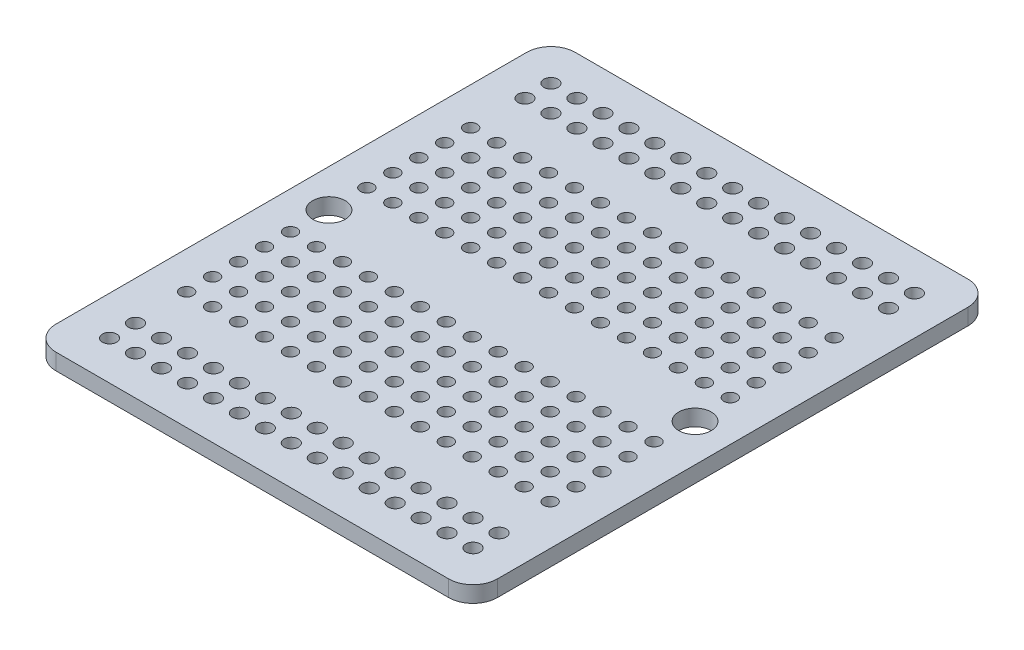
from build123d import *

# Parameters (mm, degrees)
SKETCH1_W                 = 43.18
SKETCH1_H                 = 50.8
BOSS_EXTRUDE1_DEPTH       = 1.5875
FILLET1_R                 = 2.38125
SKETCH4_R                 = 0.6985
CUT_EXTRUDE1_DEPTH        = 34.373765988
LPATTERN1_COUNT           = 15
LPATTERN1_PITCH           = 2.54
LPATTERN1_COUNT_DIR2      = 2
LPATTERN1_PITCH_DIR2      = 2.54
SKETCH5_R                 = 0.635
CUT_EXTRUDE6_DEPTH        = 34.373765988
LPATTERN2_COUNT           = 15
LPATTERN2_PITCH           = 2.54
LPATTERN2_COUNT_DIR2      = 5
LPATTERN2_PITCH_DIR2      = 2.54
MIRROR1_COPY_1_SKETCH_R   = 0.6985
MIRROR1_COPY_1_DEPTH      = 34.373765988
MIRROR1_COPY_2_SKETCH_R   = 0.6985
MIRROR1_COPY_2_DEPTH      = 34.373765988
MIRROR1_COPY_3_SKETCH_R   = 0.6985
MIRROR1_COPY_3_DEPTH      = 34.373765988
MIRROR1_COPY_4_SKETCH_R   = 0.6985
MIRROR1_COPY_4_DEPTH      = 34.373765988
MIRROR1_COPY_5_SKETCH_R   = 0.6985
MIRROR1_COPY_5_DEPTH      = 34.373765988
MIRROR1_COPY_6_SKETCH_R   = 0.6985
MIRROR1_COPY_6_DEPTH      = 34.373765988
MIRROR1_COPY_7_SKETCH_R   = 0.6985
MIRROR1_COPY_7_DEPTH      = 34.373765988
MIRROR1_COPY_8_SKETCH_R   = 0.6985
MIRROR1_COPY_8_DEPTH      = 34.373765988
MIRROR1_COPY_9_SKETCH_R   = 0.6985
MIRROR1_COPY_9_DEPTH      = 34.373765988
MIRROR1_COPY_10_SKETCH_R  = 0.6985
MIRROR1_COPY_10_DEPTH     = 34.373765988
MIRROR1_COPY_11_SKETCH_R  = 0.6985
MIRROR1_COPY_11_DEPTH     = 34.373765988
MIRROR1_COPY_12_SKETCH_R  = 0.6985
MIRROR1_COPY_12_DEPTH     = 34.373765988
MIRROR1_COPY_13_SKETCH_R  = 0.6985
MIRROR1_COPY_13_DEPTH     = 34.373765988
MIRROR1_COPY_14_SKETCH_R  = 0.6985
MIRROR1_COPY_14_DEPTH     = 34.373765988
MIRROR1_COPY_15_SKETCH_R  = 0.6985
MIRROR1_COPY_15_DEPTH     = 34.373765988
MIRROR1_COPY_16_SKETCH_R  = 0.6985
MIRROR1_COPY_16_DEPTH     = 34.373765988
MIRROR1_COPY_17_SKETCH_R  = 0.6985
MIRROR1_COPY_17_DEPTH     = 34.373765988
MIRROR1_COPY_18_SKETCH_R  = 0.6985
MIRROR1_COPY_18_DEPTH     = 34.373765988
MIRROR1_COPY_19_SKETCH_R  = 0.6985
MIRROR1_COPY_19_DEPTH     = 34.373765988
MIRROR1_COPY_20_SKETCH_R  = 0.6985
MIRROR1_COPY_20_DEPTH     = 34.373765988
MIRROR1_COPY_21_SKETCH_R  = 0.6985
MIRROR1_COPY_21_DEPTH     = 34.373765988
MIRROR1_COPY_22_SKETCH_R  = 0.6985
MIRROR1_COPY_22_DEPTH     = 34.373765988
MIRROR1_COPY_23_SKETCH_R  = 0.6985
MIRROR1_COPY_23_DEPTH     = 34.373765988
MIRROR1_COPY_24_SKETCH_R  = 0.6985
MIRROR1_COPY_24_DEPTH     = 34.373765988
MIRROR1_COPY_25_SKETCH_R  = 0.6985
MIRROR1_COPY_25_DEPTH     = 34.373765988
MIRROR1_COPY_26_SKETCH_R  = 0.6985
MIRROR1_COPY_26_DEPTH     = 34.373765988
MIRROR1_COPY_27_SKETCH_R  = 0.6985
MIRROR1_COPY_27_DEPTH     = 34.373765988
MIRROR1_COPY_28_SKETCH_R  = 0.6985
MIRROR1_COPY_28_DEPTH     = 34.373765988
MIRROR1_COPY_29_SKETCH_R  = 0.6985
MIRROR1_COPY_29_DEPTH     = 34.373765988
MIRROR1_COPY_30_SKETCH_R  = 0.635
MIRROR1_COPY_30_DEPTH     = 34.373765988
MIRROR1_COPY_31_SKETCH_R  = 0.635
MIRROR1_COPY_31_DEPTH     = 34.373765988
MIRROR1_COPY_32_SKETCH_R  = 0.635
MIRROR1_COPY_32_DEPTH     = 34.373765988
MIRROR1_COPY_33_SKETCH_R  = 0.635
MIRROR1_COPY_33_DEPTH     = 34.373765988
MIRROR1_COPY_34_SKETCH_R  = 0.635
MIRROR1_COPY_34_DEPTH     = 34.373765988
MIRROR1_COPY_35_SKETCH_R  = 0.635
MIRROR1_COPY_35_DEPTH     = 34.373765988
MIRROR1_COPY_36_SKETCH_R  = 0.635
MIRROR1_COPY_36_DEPTH     = 34.373765988
MIRROR1_COPY_37_SKETCH_R  = 0.635
MIRROR1_COPY_37_DEPTH     = 34.373765988
MIRROR1_COPY_38_SKETCH_R  = 0.635
MIRROR1_COPY_38_DEPTH     = 34.373765988
MIRROR1_COPY_39_SKETCH_R  = 0.635
MIRROR1_COPY_39_DEPTH     = 34.373765988
MIRROR1_COPY_40_SKETCH_R  = 0.635
MIRROR1_COPY_40_DEPTH     = 34.373765988
MIRROR1_COPY_41_SKETCH_R  = 0.635
MIRROR1_COPY_41_DEPTH     = 34.373765988
MIRROR1_COPY_42_SKETCH_R  = 0.635
MIRROR1_COPY_42_DEPTH     = 34.373765988
MIRROR1_COPY_43_SKETCH_R  = 0.635
MIRROR1_COPY_43_DEPTH     = 34.373765988
MIRROR1_COPY_44_SKETCH_R  = 0.635
MIRROR1_COPY_44_DEPTH     = 34.373765988
MIRROR1_COPY_45_SKETCH_R  = 0.635
MIRROR1_COPY_45_DEPTH     = 34.373765988
MIRROR1_COPY_46_SKETCH_R  = 0.635
MIRROR1_COPY_46_DEPTH     = 34.373765988
MIRROR1_COPY_47_SKETCH_R  = 0.635
MIRROR1_COPY_47_DEPTH     = 34.373765988
MIRROR1_COPY_48_SKETCH_R  = 0.635
MIRROR1_COPY_48_DEPTH     = 34.373765988
MIRROR1_COPY_49_SKETCH_R  = 0.635
MIRROR1_COPY_49_DEPTH     = 34.373765988
MIRROR1_COPY_50_SKETCH_R  = 0.635
MIRROR1_COPY_50_DEPTH     = 34.373765988
MIRROR1_COPY_51_SKETCH_R  = 0.635
MIRROR1_COPY_51_DEPTH     = 34.373765988
MIRROR1_COPY_52_SKETCH_R  = 0.635
MIRROR1_COPY_52_DEPTH     = 34.373765988
MIRROR1_COPY_53_SKETCH_R  = 0.635
MIRROR1_COPY_53_DEPTH     = 34.373765988
MIRROR1_COPY_54_SKETCH_R  = 0.635
MIRROR1_COPY_54_DEPTH     = 34.373765988
MIRROR1_COPY_55_SKETCH_R  = 0.635
MIRROR1_COPY_55_DEPTH     = 34.373765988
MIRROR1_COPY_56_SKETCH_R  = 0.635
MIRROR1_COPY_56_DEPTH     = 34.373765988
MIRROR1_COPY_57_SKETCH_R  = 0.635
MIRROR1_COPY_57_DEPTH     = 34.373765988
MIRROR1_COPY_58_SKETCH_R  = 0.635
MIRROR1_COPY_58_DEPTH     = 34.373765988
MIRROR1_COPY_59_SKETCH_R  = 0.635
MIRROR1_COPY_59_DEPTH     = 34.373765988
MIRROR1_COPY_60_SKETCH_R  = 0.635
MIRROR1_COPY_60_DEPTH     = 34.373765988
MIRROR1_COPY_61_SKETCH_R  = 0.635
MIRROR1_COPY_61_DEPTH     = 34.373765988
MIRROR1_COPY_62_SKETCH_R  = 0.635
MIRROR1_COPY_62_DEPTH     = 34.373765988
MIRROR1_COPY_63_SKETCH_R  = 0.635
MIRROR1_COPY_63_DEPTH     = 34.373765988
MIRROR1_COPY_64_SKETCH_R  = 0.635
MIRROR1_COPY_64_DEPTH     = 34.373765988
MIRROR1_COPY_65_SKETCH_R  = 0.635
MIRROR1_COPY_65_DEPTH     = 34.373765988
MIRROR1_COPY_66_SKETCH_R  = 0.635
MIRROR1_COPY_66_DEPTH     = 34.373765988
MIRROR1_COPY_67_SKETCH_R  = 0.635
MIRROR1_COPY_67_DEPTH     = 34.373765988
MIRROR1_COPY_68_SKETCH_R  = 0.635
MIRROR1_COPY_68_DEPTH     = 34.373765988
MIRROR1_COPY_69_SKETCH_R  = 0.635
MIRROR1_COPY_69_DEPTH     = 34.373765988
MIRROR1_COPY_70_SKETCH_R  = 0.635
MIRROR1_COPY_70_DEPTH     = 34.373765988
MIRROR1_COPY_71_SKETCH_R  = 0.635
MIRROR1_COPY_71_DEPTH     = 34.373765988
MIRROR1_COPY_72_SKETCH_R  = 0.635
MIRROR1_COPY_72_DEPTH     = 34.373765988
MIRROR1_COPY_73_SKETCH_R  = 0.635
MIRROR1_COPY_73_DEPTH     = 34.373765988
MIRROR1_COPY_74_SKETCH_R  = 0.635
MIRROR1_COPY_74_DEPTH     = 34.373765988
MIRROR1_COPY_75_SKETCH_R  = 0.635
MIRROR1_COPY_75_DEPTH     = 34.373765988
MIRROR1_COPY_76_SKETCH_R  = 0.635
MIRROR1_COPY_76_DEPTH     = 34.373765988
MIRROR1_COPY_77_SKETCH_R  = 0.635
MIRROR1_COPY_77_DEPTH     = 34.373765988
MIRROR1_COPY_78_SKETCH_R  = 0.635
MIRROR1_COPY_78_DEPTH     = 34.373765988
MIRROR1_COPY_79_SKETCH_R  = 0.635
MIRROR1_COPY_79_DEPTH     = 34.373765988
MIRROR1_COPY_80_SKETCH_R  = 0.635
MIRROR1_COPY_80_DEPTH     = 34.373765988
MIRROR1_COPY_81_SKETCH_R  = 0.635
MIRROR1_COPY_81_DEPTH     = 34.373765988
MIRROR1_COPY_82_SKETCH_R  = 0.635
MIRROR1_COPY_82_DEPTH     = 34.373765988
MIRROR1_COPY_83_SKETCH_R  = 0.635
MIRROR1_COPY_83_DEPTH     = 34.373765988
MIRROR1_COPY_84_SKETCH_R  = 0.635
MIRROR1_COPY_84_DEPTH     = 34.373765988
MIRROR1_COPY_85_SKETCH_R  = 0.635
MIRROR1_COPY_85_DEPTH     = 34.373765988
MIRROR1_COPY_86_SKETCH_R  = 0.635
MIRROR1_COPY_86_DEPTH     = 34.373765988
MIRROR1_COPY_87_SKETCH_R  = 0.635
MIRROR1_COPY_87_DEPTH     = 34.373765988
MIRROR1_COPY_88_SKETCH_R  = 0.635
MIRROR1_COPY_88_DEPTH     = 34.373765988
MIRROR1_COPY_89_SKETCH_R  = 0.635
MIRROR1_COPY_89_DEPTH     = 34.373765988
MIRROR1_COPY_90_SKETCH_R  = 0.635
MIRROR1_COPY_90_DEPTH     = 34.373765988
MIRROR1_COPY_91_SKETCH_R  = 0.635
MIRROR1_COPY_91_DEPTH     = 34.373765988
MIRROR1_COPY_92_SKETCH_R  = 0.635
MIRROR1_COPY_92_DEPTH     = 34.373765988
MIRROR1_COPY_93_SKETCH_R  = 0.635
MIRROR1_COPY_93_DEPTH     = 34.373765988
MIRROR1_COPY_94_SKETCH_R  = 0.635
MIRROR1_COPY_94_DEPTH     = 34.373765988
MIRROR1_COPY_95_SKETCH_R  = 0.635
MIRROR1_COPY_95_DEPTH     = 34.373765988
MIRROR1_COPY_96_SKETCH_R  = 0.635
MIRROR1_COPY_96_DEPTH     = 34.373765988
MIRROR1_COPY_97_SKETCH_R  = 0.635
MIRROR1_COPY_97_DEPTH     = 34.373765988
MIRROR1_COPY_98_SKETCH_R  = 0.635
MIRROR1_COPY_98_DEPTH     = 34.373765988
MIRROR1_COPY_99_SKETCH_R  = 0.635
MIRROR1_COPY_99_DEPTH     = 34.373765988
MIRROR1_COPY_100_SKETCH_R = 0.635
MIRROR1_COPY_100_DEPTH    = 34.373765988
MIRROR1_COPY_101_SKETCH_R = 0.635
MIRROR1_COPY_101_DEPTH    = 34.373765988
MIRROR1_COPY_102_SKETCH_R = 0.635
MIRROR1_COPY_102_DEPTH    = 34.373765988
MIRROR1_COPY_103_SKETCH_R = 0.635
MIRROR1_COPY_103_DEPTH    = 34.373765988
SKETCH6_R                 = 1.5875
CUT_EXTRUDE7_DEPTH        = 34.373765988


with BuildPart() as part:
    # Sketch1 → Boss-Extrude1 (new body)
    with BuildSketch(Plane(origin=(0, 0, 0), x_dir=(1, 0, 0), z_dir=(0, 1, 0))):
        Rectangle(SKETCH1_W, SKETCH1_H)
    extrude(amount=BOSS_EXTRUDE1_DEPTH)

    # Fillet1
    fillet1_edges = [part.edges().sort_by_distance(p)[0] for p in [
        (21.59, 0.79375, 25.4),
        (-21.59, 0.79375, 25.4),
        (-21.59, 0.79375, -25.4),
        (21.59, 0.79375, -25.4),
    ]]
    fillet(fillet1_edges, radius=FILLET1_R)

    # Sketch4 → Cut-Extrude1 (cut, through all)
    with BuildSketch(Plane(origin=(0, 1.5875, 0), x_dir=(1, 0, 0), z_dir=(0, 1, 0))):
        with Locations(Location((-17.78, 21.59, 0), (0, 0, 270))):
            Circle(SKETCH4_R)
    cut_extrude1 = extrude(amount=-CUT_EXTRUDE1_DEPTH, mode=Mode.SUBTRACT)

    # LPattern1: Cut-Extrude1 15 × 2
    with Locations(*[(i * LPATTERN1_PITCH, 0, j * LPATTERN1_PITCH_DIR2) for i in range(LPATTERN1_COUNT) for j in range(LPATTERN1_COUNT_DIR2) if (i, j) != (0, 0)]):
        add(cut_extrude1, mode=Mode.SUBTRACT)

    # Sketch5 → Cut-Extrude6 (cut, through all)
    with BuildSketch(Plane(origin=(0, 0, 0), x_dir=(1, 0, 0), z_dir=(0, 1, 0))):
        with Locations(Location((-17.935079329, 13.893307041, 0), (0, 0, 270))):
            Circle(SKETCH5_R)
    cut_extrude6 = extrude(amount=CUT_EXTRUDE6_DEPTH, mode=Mode.SUBTRACT)

    # LPattern2: Cut-Extrude6 15 × 5
    with Locations(*[(i * LPATTERN2_PITCH, 0, j * LPATTERN2_PITCH_DIR2) for i in range(LPATTERN2_COUNT) for j in range(LPATTERN2_COUNT_DIR2) if (i, j) != (0, 0)]):
        add(cut_extrude6, mode=Mode.SUBTRACT)

    # Mirror1: Cut-Extrude1, Cut-Extrude6 across plane
    add(cut_extrude1.mirror(Plane.XY), mode=Mode.SUBTRACT)
    add(cut_extrude6.mirror(Plane.XY), mode=Mode.SUBTRACT)

    # Mirror1 copy 1 sketch → Mirror1 copy 1 (cut, through all)
    with BuildSketch(Plane(origin=(0, 1.5875, -2.54), x_dir=(1, 0, 0), z_dir=(0, 1, 0))):
        with Locations((-17.78, -21.59)):
            Circle(MIRROR1_COPY_1_SKETCH_R)
    extrude(amount=-MIRROR1_COPY_1_DEPTH, mode=Mode.SUBTRACT)

    # Mirror1 copy 2 sketch → Mirror1 copy 2 (cut, through all)
    with BuildSketch(Plane(origin=(2.54, 1.5875, 0), x_dir=(1, 0, 0), z_dir=(0, 1, 0))):
        with Locations((-17.78, -21.59)):
            Circle(MIRROR1_COPY_2_SKETCH_R)
    extrude(amount=-MIRROR1_COPY_2_DEPTH, mode=Mode.SUBTRACT)

    # Mirror1 copy 3 sketch → Mirror1 copy 3 (cut, through all)
    with BuildSketch(Plane(origin=(2.54, 1.5875, -2.54), x_dir=(1, 0, 0), z_dir=(0, 1, 0))):
        with Locations((-17.78, -21.59)):
            Circle(MIRROR1_COPY_3_SKETCH_R)
    extrude(amount=-MIRROR1_COPY_3_DEPTH, mode=Mode.SUBTRACT)

    # Mirror1 copy 4 sketch → Mirror1 copy 4 (cut, through all)
    with BuildSketch(Plane(origin=(5.08, 1.5875, 0), x_dir=(1, 0, 0), z_dir=(0, 1, 0))):
        with Locations((-17.78, -21.59)):
            Circle(MIRROR1_COPY_4_SKETCH_R)
    extrude(amount=-MIRROR1_COPY_4_DEPTH, mode=Mode.SUBTRACT)

    # Mirror1 copy 5 sketch → Mirror1 copy 5 (cut, through all)
    with BuildSketch(Plane(origin=(5.08, 1.5875, -2.54), x_dir=(1, 0, 0), z_dir=(0, 1, 0))):
        with Locations((-17.78, -21.59)):
            Circle(MIRROR1_COPY_5_SKETCH_R)
    extrude(amount=-MIRROR1_COPY_5_DEPTH, mode=Mode.SUBTRACT)

    # Mirror1 copy 6 sketch → Mirror1 copy 6 (cut, through all)
    with BuildSketch(Plane(origin=(7.62, 1.5875, 0), x_dir=(1, 0, 0), z_dir=(0, 1, 0))):
        with Locations((-17.78, -21.59)):
            Circle(MIRROR1_COPY_6_SKETCH_R)
    extrude(amount=-MIRROR1_COPY_6_DEPTH, mode=Mode.SUBTRACT)

    # Mirror1 copy 7 sketch → Mirror1 copy 7 (cut, through all)
    with BuildSketch(Plane(origin=(7.62, 1.5875, -2.54), x_dir=(1, 0, 0), z_dir=(0, 1, 0))):
        with Locations((-17.78, -21.59)):
            Circle(MIRROR1_COPY_7_SKETCH_R)
    extrude(amount=-MIRROR1_COPY_7_DEPTH, mode=Mode.SUBTRACT)

    # Mirror1 copy 8 sketch → Mirror1 copy 8 (cut, through all)
    with BuildSketch(Plane(origin=(10.16, 1.5875, 0), x_dir=(1, 0, 0), z_dir=(0, 1, 0))):
        with Locations((-17.78, -21.59)):
            Circle(MIRROR1_COPY_8_SKETCH_R)
    extrude(amount=-MIRROR1_COPY_8_DEPTH, mode=Mode.SUBTRACT)

    # Mirror1 copy 9 sketch → Mirror1 copy 9 (cut, through all)
    with BuildSketch(Plane(origin=(10.16, 1.5875, -2.54), x_dir=(1, 0, 0), z_dir=(0, 1, 0))):
        with Locations((-17.78, -21.59)):
            Circle(MIRROR1_COPY_9_SKETCH_R)
    extrude(amount=-MIRROR1_COPY_9_DEPTH, mode=Mode.SUBTRACT)

    # Mirror1 copy 10 sketch → Mirror1 copy 10 (cut, through all)
    with BuildSketch(Plane(origin=(12.7, 1.5875, 0), x_dir=(1, 0, 0), z_dir=(0, 1, 0))):
        with Locations((-17.78, -21.59)):
            Circle(MIRROR1_COPY_10_SKETCH_R)
    extrude(amount=-MIRROR1_COPY_10_DEPTH, mode=Mode.SUBTRACT)

    # Mirror1 copy 11 sketch → Mirror1 copy 11 (cut, through all)
    with BuildSketch(Plane(origin=(12.7, 1.5875, -2.54), x_dir=(1, 0, 0), z_dir=(0, 1, 0))):
        with Locations((-17.78, -21.59)):
            Circle(MIRROR1_COPY_11_SKETCH_R)
    extrude(amount=-MIRROR1_COPY_11_DEPTH, mode=Mode.SUBTRACT)

    # Mirror1 copy 12 sketch → Mirror1 copy 12 (cut, through all)
    with BuildSketch(Plane(origin=(15.24, 1.5875, 0), x_dir=(1, 0, 0), z_dir=(0, 1, 0))):
        with Locations((-17.78, -21.59)):
            Circle(MIRROR1_COPY_12_SKETCH_R)
    extrude(amount=-MIRROR1_COPY_12_DEPTH, mode=Mode.SUBTRACT)

    # Mirror1 copy 13 sketch → Mirror1 copy 13 (cut, through all)
    with BuildSketch(Plane(origin=(15.24, 1.5875, -2.54), x_dir=(1, 0, 0), z_dir=(0, 1, 0))):
        with Locations((-17.78, -21.59)):
            Circle(MIRROR1_COPY_13_SKETCH_R)
    extrude(amount=-MIRROR1_COPY_13_DEPTH, mode=Mode.SUBTRACT)

    # Mirror1 copy 14 sketch → Mirror1 copy 14 (cut, through all)
    with BuildSketch(Plane(origin=(17.78, 1.5875, 0), x_dir=(1, 0, 0), z_dir=(0, 1, 0))):
        with Locations((-17.78, -21.59)):
            Circle(MIRROR1_COPY_14_SKETCH_R)
    extrude(amount=-MIRROR1_COPY_14_DEPTH, mode=Mode.SUBTRACT)

    # Mirror1 copy 15 sketch → Mirror1 copy 15 (cut, through all)
    with BuildSketch(Plane(origin=(17.78, 1.5875, -2.54), x_dir=(1, 0, 0), z_dir=(0, 1, 0))):
        with Locations((-17.78, -21.59)):
            Circle(MIRROR1_COPY_15_SKETCH_R)
    extrude(amount=-MIRROR1_COPY_15_DEPTH, mode=Mode.SUBTRACT)

    # Mirror1 copy 16 sketch → Mirror1 copy 16 (cut, through all)
    with BuildSketch(Plane(origin=(20.32, 1.5875, 0), x_dir=(1, 0, 0), z_dir=(0, 1, 0))):
        with Locations((-17.78, -21.59)):
            Circle(MIRROR1_COPY_16_SKETCH_R)
    extrude(amount=-MIRROR1_COPY_16_DEPTH, mode=Mode.SUBTRACT)

    # Mirror1 copy 17 sketch → Mirror1 copy 17 (cut, through all)
    with BuildSketch(Plane(origin=(20.32, 1.5875, -2.54), x_dir=(1, 0, 0), z_dir=(0, 1, 0))):
        with Locations((-17.78, -21.59)):
            Circle(MIRROR1_COPY_17_SKETCH_R)
    extrude(amount=-MIRROR1_COPY_17_DEPTH, mode=Mode.SUBTRACT)

    # Mirror1 copy 18 sketch → Mirror1 copy 18 (cut, through all)
    with BuildSketch(Plane(origin=(22.86, 1.5875, 0), x_dir=(1, 0, 0), z_dir=(0, 1, 0))):
        with Locations((-17.78, -21.59)):
            Circle(MIRROR1_COPY_18_SKETCH_R)
    extrude(amount=-MIRROR1_COPY_18_DEPTH, mode=Mode.SUBTRACT)

    # Mirror1 copy 19 sketch → Mirror1 copy 19 (cut, through all)
    with BuildSketch(Plane(origin=(22.86, 1.5875, -2.54), x_dir=(1, 0, 0), z_dir=(0, 1, 0))):
        with Locations((-17.78, -21.59)):
            Circle(MIRROR1_COPY_19_SKETCH_R)
    extrude(amount=-MIRROR1_COPY_19_DEPTH, mode=Mode.SUBTRACT)

    # Mirror1 copy 20 sketch → Mirror1 copy 20 (cut, through all)
    with BuildSketch(Plane(origin=(25.4, 1.5875, 0), x_dir=(1, 0, 0), z_dir=(0, 1, 0))):
        with Locations((-17.78, -21.59)):
            Circle(MIRROR1_COPY_20_SKETCH_R)
    extrude(amount=-MIRROR1_COPY_20_DEPTH, mode=Mode.SUBTRACT)

    # Mirror1 copy 21 sketch → Mirror1 copy 21 (cut, through all)
    with BuildSketch(Plane(origin=(25.4, 1.5875, -2.54), x_dir=(1, 0, 0), z_dir=(0, 1, 0))):
        with Locations((-17.78, -21.59)):
            Circle(MIRROR1_COPY_21_SKETCH_R)
    extrude(amount=-MIRROR1_COPY_21_DEPTH, mode=Mode.SUBTRACT)

    # Mirror1 copy 22 sketch → Mirror1 copy 22 (cut, through all)
    with BuildSketch(Plane(origin=(27.94, 1.5875, 0), x_dir=(1, 0, 0), z_dir=(0, 1, 0))):
        with Locations((-17.78, -21.59)):
            Circle(MIRROR1_COPY_22_SKETCH_R)
    extrude(amount=-MIRROR1_COPY_22_DEPTH, mode=Mode.SUBTRACT)

    # Mirror1 copy 23 sketch → Mirror1 copy 23 (cut, through all)
    with BuildSketch(Plane(origin=(27.94, 1.5875, -2.54), x_dir=(1, 0, 0), z_dir=(0, 1, 0))):
        with Locations((-17.78, -21.59)):
            Circle(MIRROR1_COPY_23_SKETCH_R)
    extrude(amount=-MIRROR1_COPY_23_DEPTH, mode=Mode.SUBTRACT)

    # Mirror1 copy 24 sketch → Mirror1 copy 24 (cut, through all)
    with BuildSketch(Plane(origin=(30.48, 1.5875, 0), x_dir=(1, 0, 0), z_dir=(0, 1, 0))):
        with Locations((-17.78, -21.59)):
            Circle(MIRROR1_COPY_24_SKETCH_R)
    extrude(amount=-MIRROR1_COPY_24_DEPTH, mode=Mode.SUBTRACT)

    # Mirror1 copy 25 sketch → Mirror1 copy 25 (cut, through all)
    with BuildSketch(Plane(origin=(30.48, 1.5875, -2.54), x_dir=(1, 0, 0), z_dir=(0, 1, 0))):
        with Locations((-17.78, -21.59)):
            Circle(MIRROR1_COPY_25_SKETCH_R)
    extrude(amount=-MIRROR1_COPY_25_DEPTH, mode=Mode.SUBTRACT)

    # Mirror1 copy 26 sketch → Mirror1 copy 26 (cut, through all)
    with BuildSketch(Plane(origin=(33.02, 1.5875, 0), x_dir=(1, 0, 0), z_dir=(0, 1, 0))):
        with Locations((-17.78, -21.59)):
            Circle(MIRROR1_COPY_26_SKETCH_R)
    extrude(amount=-MIRROR1_COPY_26_DEPTH, mode=Mode.SUBTRACT)

    # Mirror1 copy 27 sketch → Mirror1 copy 27 (cut, through all)
    with BuildSketch(Plane(origin=(33.02, 1.5875, -2.54), x_dir=(1, 0, 0), z_dir=(0, 1, 0))):
        with Locations((-17.78, -21.59)):
            Circle(MIRROR1_COPY_27_SKETCH_R)
    extrude(amount=-MIRROR1_COPY_27_DEPTH, mode=Mode.SUBTRACT)

    # Mirror1 copy 28 sketch → Mirror1 copy 28 (cut, through all)
    with BuildSketch(Plane(origin=(35.56, 1.5875, 0), x_dir=(1, 0, 0), z_dir=(0, 1, 0))):
        with Locations((-17.78, -21.59)):
            Circle(MIRROR1_COPY_28_SKETCH_R)
    extrude(amount=-MIRROR1_COPY_28_DEPTH, mode=Mode.SUBTRACT)

    # Mirror1 copy 29 sketch → Mirror1 copy 29 (cut, through all)
    with BuildSketch(Plane(origin=(35.56, 1.5875, -2.54), x_dir=(1, 0, 0), z_dir=(0, 1, 0))):
        with Locations((-17.78, -21.59)):
            Circle(MIRROR1_COPY_29_SKETCH_R)
    extrude(amount=-MIRROR1_COPY_29_DEPTH, mode=Mode.SUBTRACT)

    # Mirror1 copy 30 sketch → Mirror1 copy 30 (cut, through all)
    with BuildSketch(Plane(origin=(0, 0, -2.54), x_dir=(1, 0, 0), z_dir=(0, 1, 0))):
        with Locations((-17.935079329, -13.893307041)):
            Circle(MIRROR1_COPY_30_SKETCH_R)
    extrude(amount=MIRROR1_COPY_30_DEPTH, mode=Mode.SUBTRACT)

    # Mirror1 copy 31 sketch → Mirror1 copy 31 (cut, through all)
    with BuildSketch(Plane(origin=(0, 0, -5.08), x_dir=(1, 0, 0), z_dir=(0, 1, 0))):
        with Locations((-17.935079329, -13.893307041)):
            Circle(MIRROR1_COPY_31_SKETCH_R)
    extrude(amount=MIRROR1_COPY_31_DEPTH, mode=Mode.SUBTRACT)

    # Mirror1 copy 32 sketch → Mirror1 copy 32 (cut, through all)
    with BuildSketch(Plane(origin=(0, 0, -7.62), x_dir=(1, 0, 0), z_dir=(0, 1, 0))):
        with Locations((-17.935079329, -13.893307041)):
            Circle(MIRROR1_COPY_32_SKETCH_R)
    extrude(amount=MIRROR1_COPY_32_DEPTH, mode=Mode.SUBTRACT)

    # Mirror1 copy 33 sketch → Mirror1 copy 33 (cut, through all)
    with BuildSketch(Plane(origin=(0, 0, -10.16), x_dir=(1, 0, 0), z_dir=(0, 1, 0))):
        with Locations((-17.935079329, -13.893307041)):
            Circle(MIRROR1_COPY_33_SKETCH_R)
    extrude(amount=MIRROR1_COPY_33_DEPTH, mode=Mode.SUBTRACT)

    # Mirror1 copy 34 sketch → Mirror1 copy 34 (cut, through all)
    with BuildSketch(Plane(origin=(2.54, 0, 0), x_dir=(1, 0, 0), z_dir=(0, 1, 0))):
        with Locations((-17.935079329, -13.893307041)):
            Circle(MIRROR1_COPY_34_SKETCH_R)
    extrude(amount=MIRROR1_COPY_34_DEPTH, mode=Mode.SUBTRACT)

    # Mirror1 copy 35 sketch → Mirror1 copy 35 (cut, through all)
    with BuildSketch(Plane(origin=(2.54, 0, -2.54), x_dir=(1, 0, 0), z_dir=(0, 1, 0))):
        with Locations((-17.935079329, -13.893307041)):
            Circle(MIRROR1_COPY_35_SKETCH_R)
    extrude(amount=MIRROR1_COPY_35_DEPTH, mode=Mode.SUBTRACT)

    # Mirror1 copy 36 sketch → Mirror1 copy 36 (cut, through all)
    with BuildSketch(Plane(origin=(2.54, 0, -5.08), x_dir=(1, 0, 0), z_dir=(0, 1, 0))):
        with Locations((-17.935079329, -13.893307041)):
            Circle(MIRROR1_COPY_36_SKETCH_R)
    extrude(amount=MIRROR1_COPY_36_DEPTH, mode=Mode.SUBTRACT)

    # Mirror1 copy 37 sketch → Mirror1 copy 37 (cut, through all)
    with BuildSketch(Plane(origin=(2.54, 0, -7.62), x_dir=(1, 0, 0), z_dir=(0, 1, 0))):
        with Locations((-17.935079329, -13.893307041)):
            Circle(MIRROR1_COPY_37_SKETCH_R)
    extrude(amount=MIRROR1_COPY_37_DEPTH, mode=Mode.SUBTRACT)

    # Mirror1 copy 38 sketch → Mirror1 copy 38 (cut, through all)
    with BuildSketch(Plane(origin=(2.54, 0, -10.16), x_dir=(1, 0, 0), z_dir=(0, 1, 0))):
        with Locations((-17.935079329, -13.893307041)):
            Circle(MIRROR1_COPY_38_SKETCH_R)
    extrude(amount=MIRROR1_COPY_38_DEPTH, mode=Mode.SUBTRACT)

    # Mirror1 copy 39 sketch → Mirror1 copy 39 (cut, through all)
    with BuildSketch(Plane(origin=(5.08, 0, 0), x_dir=(1, 0, 0), z_dir=(0, 1, 0))):
        with Locations((-17.935079329, -13.893307041)):
            Circle(MIRROR1_COPY_39_SKETCH_R)
    extrude(amount=MIRROR1_COPY_39_DEPTH, mode=Mode.SUBTRACT)

    # Mirror1 copy 40 sketch → Mirror1 copy 40 (cut, through all)
    with BuildSketch(Plane(origin=(5.08, 0, -2.54), x_dir=(1, 0, 0), z_dir=(0, 1, 0))):
        with Locations((-17.935079329, -13.893307041)):
            Circle(MIRROR1_COPY_40_SKETCH_R)
    extrude(amount=MIRROR1_COPY_40_DEPTH, mode=Mode.SUBTRACT)

    # Mirror1 copy 41 sketch → Mirror1 copy 41 (cut, through all)
    with BuildSketch(Plane(origin=(5.08, 0, -5.08), x_dir=(1, 0, 0), z_dir=(0, 1, 0))):
        with Locations((-17.935079329, -13.893307041)):
            Circle(MIRROR1_COPY_41_SKETCH_R)
    extrude(amount=MIRROR1_COPY_41_DEPTH, mode=Mode.SUBTRACT)

    # Mirror1 copy 42 sketch → Mirror1 copy 42 (cut, through all)
    with BuildSketch(Plane(origin=(5.08, 0, -7.62), x_dir=(1, 0, 0), z_dir=(0, 1, 0))):
        with Locations((-17.935079329, -13.893307041)):
            Circle(MIRROR1_COPY_42_SKETCH_R)
    extrude(amount=MIRROR1_COPY_42_DEPTH, mode=Mode.SUBTRACT)

    # Mirror1 copy 43 sketch → Mirror1 copy 43 (cut, through all)
    with BuildSketch(Plane(origin=(5.08, 0, -10.16), x_dir=(1, 0, 0), z_dir=(0, 1, 0))):
        with Locations((-17.935079329, -13.893307041)):
            Circle(MIRROR1_COPY_43_SKETCH_R)
    extrude(amount=MIRROR1_COPY_43_DEPTH, mode=Mode.SUBTRACT)

    # Mirror1 copy 44 sketch → Mirror1 copy 44 (cut, through all)
    with BuildSketch(Plane(origin=(7.62, 0, 0), x_dir=(1, 0, 0), z_dir=(0, 1, 0))):
        with Locations((-17.935079329, -13.893307041)):
            Circle(MIRROR1_COPY_44_SKETCH_R)
    extrude(amount=MIRROR1_COPY_44_DEPTH, mode=Mode.SUBTRACT)

    # Mirror1 copy 45 sketch → Mirror1 copy 45 (cut, through all)
    with BuildSketch(Plane(origin=(7.62, 0, -2.54), x_dir=(1, 0, 0), z_dir=(0, 1, 0))):
        with Locations((-17.935079329, -13.893307041)):
            Circle(MIRROR1_COPY_45_SKETCH_R)
    extrude(amount=MIRROR1_COPY_45_DEPTH, mode=Mode.SUBTRACT)

    # Mirror1 copy 46 sketch → Mirror1 copy 46 (cut, through all)
    with BuildSketch(Plane(origin=(7.62, 0, -5.08), x_dir=(1, 0, 0), z_dir=(0, 1, 0))):
        with Locations((-17.935079329, -13.893307041)):
            Circle(MIRROR1_COPY_46_SKETCH_R)
    extrude(amount=MIRROR1_COPY_46_DEPTH, mode=Mode.SUBTRACT)

    # Mirror1 copy 47 sketch → Mirror1 copy 47 (cut, through all)
    with BuildSketch(Plane(origin=(7.62, 0, -7.62), x_dir=(1, 0, 0), z_dir=(0, 1, 0))):
        with Locations((-17.935079329, -13.893307041)):
            Circle(MIRROR1_COPY_47_SKETCH_R)
    extrude(amount=MIRROR1_COPY_47_DEPTH, mode=Mode.SUBTRACT)

    # Mirror1 copy 48 sketch → Mirror1 copy 48 (cut, through all)
    with BuildSketch(Plane(origin=(7.62, 0, -10.16), x_dir=(1, 0, 0), z_dir=(0, 1, 0))):
        with Locations((-17.935079329, -13.893307041)):
            Circle(MIRROR1_COPY_48_SKETCH_R)
    extrude(amount=MIRROR1_COPY_48_DEPTH, mode=Mode.SUBTRACT)

    # Mirror1 copy 49 sketch → Mirror1 copy 49 (cut, through all)
    with BuildSketch(Plane(origin=(10.16, 0, 0), x_dir=(1, 0, 0), z_dir=(0, 1, 0))):
        with Locations((-17.935079329, -13.893307041)):
            Circle(MIRROR1_COPY_49_SKETCH_R)
    extrude(amount=MIRROR1_COPY_49_DEPTH, mode=Mode.SUBTRACT)

    # Mirror1 copy 50 sketch → Mirror1 copy 50 (cut, through all)
    with BuildSketch(Plane(origin=(10.16, 0, -2.54), x_dir=(1, 0, 0), z_dir=(0, 1, 0))):
        with Locations((-17.935079329, -13.893307041)):
            Circle(MIRROR1_COPY_50_SKETCH_R)
    extrude(amount=MIRROR1_COPY_50_DEPTH, mode=Mode.SUBTRACT)

    # Mirror1 copy 51 sketch → Mirror1 copy 51 (cut, through all)
    with BuildSketch(Plane(origin=(10.16, 0, -5.08), x_dir=(1, 0, 0), z_dir=(0, 1, 0))):
        with Locations((-17.935079329, -13.893307041)):
            Circle(MIRROR1_COPY_51_SKETCH_R)
    extrude(amount=MIRROR1_COPY_51_DEPTH, mode=Mode.SUBTRACT)

    # Mirror1 copy 52 sketch → Mirror1 copy 52 (cut, through all)
    with BuildSketch(Plane(origin=(10.16, 0, -7.62), x_dir=(1, 0, 0), z_dir=(0, 1, 0))):
        with Locations((-17.935079329, -13.893307041)):
            Circle(MIRROR1_COPY_52_SKETCH_R)
    extrude(amount=MIRROR1_COPY_52_DEPTH, mode=Mode.SUBTRACT)

    # Mirror1 copy 53 sketch → Mirror1 copy 53 (cut, through all)
    with BuildSketch(Plane(origin=(10.16, 0, -10.16), x_dir=(1, 0, 0), z_dir=(0, 1, 0))):
        with Locations((-17.935079329, -13.893307041)):
            Circle(MIRROR1_COPY_53_SKETCH_R)
    extrude(amount=MIRROR1_COPY_53_DEPTH, mode=Mode.SUBTRACT)

    # Mirror1 copy 54 sketch → Mirror1 copy 54 (cut, through all)
    with BuildSketch(Plane(origin=(12.7, 0, 0), x_dir=(1, 0, 0), z_dir=(0, 1, 0))):
        with Locations((-17.935079329, -13.893307041)):
            Circle(MIRROR1_COPY_54_SKETCH_R)
    extrude(amount=MIRROR1_COPY_54_DEPTH, mode=Mode.SUBTRACT)

    # Mirror1 copy 55 sketch → Mirror1 copy 55 (cut, through all)
    with BuildSketch(Plane(origin=(12.7, 0, -2.54), x_dir=(1, 0, 0), z_dir=(0, 1, 0))):
        with Locations((-17.935079329, -13.893307041)):
            Circle(MIRROR1_COPY_55_SKETCH_R)
    extrude(amount=MIRROR1_COPY_55_DEPTH, mode=Mode.SUBTRACT)

    # Mirror1 copy 56 sketch → Mirror1 copy 56 (cut, through all)
    with BuildSketch(Plane(origin=(12.7, 0, -5.08), x_dir=(1, 0, 0), z_dir=(0, 1, 0))):
        with Locations((-17.935079329, -13.893307041)):
            Circle(MIRROR1_COPY_56_SKETCH_R)
    extrude(amount=MIRROR1_COPY_56_DEPTH, mode=Mode.SUBTRACT)

    # Mirror1 copy 57 sketch → Mirror1 copy 57 (cut, through all)
    with BuildSketch(Plane(origin=(12.7, 0, -7.62), x_dir=(1, 0, 0), z_dir=(0, 1, 0))):
        with Locations((-17.935079329, -13.893307041)):
            Circle(MIRROR1_COPY_57_SKETCH_R)
    extrude(amount=MIRROR1_COPY_57_DEPTH, mode=Mode.SUBTRACT)

    # Mirror1 copy 58 sketch → Mirror1 copy 58 (cut, through all)
    with BuildSketch(Plane(origin=(12.7, 0, -10.16), x_dir=(1, 0, 0), z_dir=(0, 1, 0))):
        with Locations((-17.935079329, -13.893307041)):
            Circle(MIRROR1_COPY_58_SKETCH_R)
    extrude(amount=MIRROR1_COPY_58_DEPTH, mode=Mode.SUBTRACT)

    # Mirror1 copy 59 sketch → Mirror1 copy 59 (cut, through all)
    with BuildSketch(Plane(origin=(15.24, 0, 0), x_dir=(1, 0, 0), z_dir=(0, 1, 0))):
        with Locations((-17.935079329, -13.893307041)):
            Circle(MIRROR1_COPY_59_SKETCH_R)
    extrude(amount=MIRROR1_COPY_59_DEPTH, mode=Mode.SUBTRACT)

    # Mirror1 copy 60 sketch → Mirror1 copy 60 (cut, through all)
    with BuildSketch(Plane(origin=(15.24, 0, -2.54), x_dir=(1, 0, 0), z_dir=(0, 1, 0))):
        with Locations((-17.935079329, -13.893307041)):
            Circle(MIRROR1_COPY_60_SKETCH_R)
    extrude(amount=MIRROR1_COPY_60_DEPTH, mode=Mode.SUBTRACT)

    # Mirror1 copy 61 sketch → Mirror1 copy 61 (cut, through all)
    with BuildSketch(Plane(origin=(15.24, 0, -5.08), x_dir=(1, 0, 0), z_dir=(0, 1, 0))):
        with Locations((-17.935079329, -13.893307041)):
            Circle(MIRROR1_COPY_61_SKETCH_R)
    extrude(amount=MIRROR1_COPY_61_DEPTH, mode=Mode.SUBTRACT)

    # Mirror1 copy 62 sketch → Mirror1 copy 62 (cut, through all)
    with BuildSketch(Plane(origin=(15.24, 0, -7.62), x_dir=(1, 0, 0), z_dir=(0, 1, 0))):
        with Locations((-17.935079329, -13.893307041)):
            Circle(MIRROR1_COPY_62_SKETCH_R)
    extrude(amount=MIRROR1_COPY_62_DEPTH, mode=Mode.SUBTRACT)

    # Mirror1 copy 63 sketch → Mirror1 copy 63 (cut, through all)
    with BuildSketch(Plane(origin=(15.24, 0, -10.16), x_dir=(1, 0, 0), z_dir=(0, 1, 0))):
        with Locations((-17.935079329, -13.893307041)):
            Circle(MIRROR1_COPY_63_SKETCH_R)
    extrude(amount=MIRROR1_COPY_63_DEPTH, mode=Mode.SUBTRACT)

    # Mirror1 copy 64 sketch → Mirror1 copy 64 (cut, through all)
    with BuildSketch(Plane(origin=(17.78, 0, 0), x_dir=(1, 0, 0), z_dir=(0, 1, 0))):
        with Locations((-17.935079329, -13.893307041)):
            Circle(MIRROR1_COPY_64_SKETCH_R)
    extrude(amount=MIRROR1_COPY_64_DEPTH, mode=Mode.SUBTRACT)

    # Mirror1 copy 65 sketch → Mirror1 copy 65 (cut, through all)
    with BuildSketch(Plane(origin=(17.78, 0, -2.54), x_dir=(1, 0, 0), z_dir=(0, 1, 0))):
        with Locations((-17.935079329, -13.893307041)):
            Circle(MIRROR1_COPY_65_SKETCH_R)
    extrude(amount=MIRROR1_COPY_65_DEPTH, mode=Mode.SUBTRACT)

    # Mirror1 copy 66 sketch → Mirror1 copy 66 (cut, through all)
    with BuildSketch(Plane(origin=(17.78, 0, -5.08), x_dir=(1, 0, 0), z_dir=(0, 1, 0))):
        with Locations((-17.935079329, -13.893307041)):
            Circle(MIRROR1_COPY_66_SKETCH_R)
    extrude(amount=MIRROR1_COPY_66_DEPTH, mode=Mode.SUBTRACT)

    # Mirror1 copy 67 sketch → Mirror1 copy 67 (cut, through all)
    with BuildSketch(Plane(origin=(17.78, 0, -7.62), x_dir=(1, 0, 0), z_dir=(0, 1, 0))):
        with Locations((-17.935079329, -13.893307041)):
            Circle(MIRROR1_COPY_67_SKETCH_R)
    extrude(amount=MIRROR1_COPY_67_DEPTH, mode=Mode.SUBTRACT)

    # Mirror1 copy 68 sketch → Mirror1 copy 68 (cut, through all)
    with BuildSketch(Plane(origin=(17.78, 0, -10.16), x_dir=(1, 0, 0), z_dir=(0, 1, 0))):
        with Locations((-17.935079329, -13.893307041)):
            Circle(MIRROR1_COPY_68_SKETCH_R)
    extrude(amount=MIRROR1_COPY_68_DEPTH, mode=Mode.SUBTRACT)

    # Mirror1 copy 69 sketch → Mirror1 copy 69 (cut, through all)
    with BuildSketch(Plane(origin=(20.32, 0, 0), x_dir=(1, 0, 0), z_dir=(0, 1, 0))):
        with Locations((-17.935079329, -13.893307041)):
            Circle(MIRROR1_COPY_69_SKETCH_R)
    extrude(amount=MIRROR1_COPY_69_DEPTH, mode=Mode.SUBTRACT)

    # Mirror1 copy 70 sketch → Mirror1 copy 70 (cut, through all)
    with BuildSketch(Plane(origin=(20.32, 0, -2.54), x_dir=(1, 0, 0), z_dir=(0, 1, 0))):
        with Locations((-17.935079329, -13.893307041)):
            Circle(MIRROR1_COPY_70_SKETCH_R)
    extrude(amount=MIRROR1_COPY_70_DEPTH, mode=Mode.SUBTRACT)

    # Mirror1 copy 71 sketch → Mirror1 copy 71 (cut, through all)
    with BuildSketch(Plane(origin=(20.32, 0, -5.08), x_dir=(1, 0, 0), z_dir=(0, 1, 0))):
        with Locations((-17.935079329, -13.893307041)):
            Circle(MIRROR1_COPY_71_SKETCH_R)
    extrude(amount=MIRROR1_COPY_71_DEPTH, mode=Mode.SUBTRACT)

    # Mirror1 copy 72 sketch → Mirror1 copy 72 (cut, through all)
    with BuildSketch(Plane(origin=(20.32, 0, -7.62), x_dir=(1, 0, 0), z_dir=(0, 1, 0))):
        with Locations((-17.935079329, -13.893307041)):
            Circle(MIRROR1_COPY_72_SKETCH_R)
    extrude(amount=MIRROR1_COPY_72_DEPTH, mode=Mode.SUBTRACT)

    # Mirror1 copy 73 sketch → Mirror1 copy 73 (cut, through all)
    with BuildSketch(Plane(origin=(20.32, 0, -10.16), x_dir=(1, 0, 0), z_dir=(0, 1, 0))):
        with Locations((-17.935079329, -13.893307041)):
            Circle(MIRROR1_COPY_73_SKETCH_R)
    extrude(amount=MIRROR1_COPY_73_DEPTH, mode=Mode.SUBTRACT)

    # Mirror1 copy 74 sketch → Mirror1 copy 74 (cut, through all)
    with BuildSketch(Plane(origin=(22.86, 0, 0), x_dir=(1, 0, 0), z_dir=(0, 1, 0))):
        with Locations((-17.935079329, -13.893307041)):
            Circle(MIRROR1_COPY_74_SKETCH_R)
    extrude(amount=MIRROR1_COPY_74_DEPTH, mode=Mode.SUBTRACT)

    # Mirror1 copy 75 sketch → Mirror1 copy 75 (cut, through all)
    with BuildSketch(Plane(origin=(22.86, 0, -2.54), x_dir=(1, 0, 0), z_dir=(0, 1, 0))):
        with Locations((-17.935079329, -13.893307041)):
            Circle(MIRROR1_COPY_75_SKETCH_R)
    extrude(amount=MIRROR1_COPY_75_DEPTH, mode=Mode.SUBTRACT)

    # Mirror1 copy 76 sketch → Mirror1 copy 76 (cut, through all)
    with BuildSketch(Plane(origin=(22.86, 0, -5.08), x_dir=(1, 0, 0), z_dir=(0, 1, 0))):
        with Locations((-17.935079329, -13.893307041)):
            Circle(MIRROR1_COPY_76_SKETCH_R)
    extrude(amount=MIRROR1_COPY_76_DEPTH, mode=Mode.SUBTRACT)

    # Mirror1 copy 77 sketch → Mirror1 copy 77 (cut, through all)
    with BuildSketch(Plane(origin=(22.86, 0, -7.62), x_dir=(1, 0, 0), z_dir=(0, 1, 0))):
        with Locations((-17.935079329, -13.893307041)):
            Circle(MIRROR1_COPY_77_SKETCH_R)
    extrude(amount=MIRROR1_COPY_77_DEPTH, mode=Mode.SUBTRACT)

    # Mirror1 copy 78 sketch → Mirror1 copy 78 (cut, through all)
    with BuildSketch(Plane(origin=(22.86, 0, -10.16), x_dir=(1, 0, 0), z_dir=(0, 1, 0))):
        with Locations((-17.935079329, -13.893307041)):
            Circle(MIRROR1_COPY_78_SKETCH_R)
    extrude(amount=MIRROR1_COPY_78_DEPTH, mode=Mode.SUBTRACT)

    # Mirror1 copy 79 sketch → Mirror1 copy 79 (cut, through all)
    with BuildSketch(Plane(origin=(25.4, 0, 0), x_dir=(1, 0, 0), z_dir=(0, 1, 0))):
        with Locations((-17.935079329, -13.893307041)):
            Circle(MIRROR1_COPY_79_SKETCH_R)
    extrude(amount=MIRROR1_COPY_79_DEPTH, mode=Mode.SUBTRACT)

    # Mirror1 copy 80 sketch → Mirror1 copy 80 (cut, through all)
    with BuildSketch(Plane(origin=(25.4, 0, -2.54), x_dir=(1, 0, 0), z_dir=(0, 1, 0))):
        with Locations((-17.935079329, -13.893307041)):
            Circle(MIRROR1_COPY_80_SKETCH_R)
    extrude(amount=MIRROR1_COPY_80_DEPTH, mode=Mode.SUBTRACT)

    # Mirror1 copy 81 sketch → Mirror1 copy 81 (cut, through all)
    with BuildSketch(Plane(origin=(25.4, 0, -5.08), x_dir=(1, 0, 0), z_dir=(0, 1, 0))):
        with Locations((-17.935079329, -13.893307041)):
            Circle(MIRROR1_COPY_81_SKETCH_R)
    extrude(amount=MIRROR1_COPY_81_DEPTH, mode=Mode.SUBTRACT)

    # Mirror1 copy 82 sketch → Mirror1 copy 82 (cut, through all)
    with BuildSketch(Plane(origin=(25.4, 0, -7.62), x_dir=(1, 0, 0), z_dir=(0, 1, 0))):
        with Locations((-17.935079329, -13.893307041)):
            Circle(MIRROR1_COPY_82_SKETCH_R)
    extrude(amount=MIRROR1_COPY_82_DEPTH, mode=Mode.SUBTRACT)

    # Mirror1 copy 83 sketch → Mirror1 copy 83 (cut, through all)
    with BuildSketch(Plane(origin=(25.4, 0, -10.16), x_dir=(1, 0, 0), z_dir=(0, 1, 0))):
        with Locations((-17.935079329, -13.893307041)):
            Circle(MIRROR1_COPY_83_SKETCH_R)
    extrude(amount=MIRROR1_COPY_83_DEPTH, mode=Mode.SUBTRACT)

    # Mirror1 copy 84 sketch → Mirror1 copy 84 (cut, through all)
    with BuildSketch(Plane(origin=(27.94, 0, 0), x_dir=(1, 0, 0), z_dir=(0, 1, 0))):
        with Locations((-17.935079329, -13.893307041)):
            Circle(MIRROR1_COPY_84_SKETCH_R)
    extrude(amount=MIRROR1_COPY_84_DEPTH, mode=Mode.SUBTRACT)

    # Mirror1 copy 85 sketch → Mirror1 copy 85 (cut, through all)
    with BuildSketch(Plane(origin=(27.94, 0, -2.54), x_dir=(1, 0, 0), z_dir=(0, 1, 0))):
        with Locations((-17.935079329, -13.893307041)):
            Circle(MIRROR1_COPY_85_SKETCH_R)
    extrude(amount=MIRROR1_COPY_85_DEPTH, mode=Mode.SUBTRACT)

    # Mirror1 copy 86 sketch → Mirror1 copy 86 (cut, through all)
    with BuildSketch(Plane(origin=(27.94, 0, -5.08), x_dir=(1, 0, 0), z_dir=(0, 1, 0))):
        with Locations((-17.935079329, -13.893307041)):
            Circle(MIRROR1_COPY_86_SKETCH_R)
    extrude(amount=MIRROR1_COPY_86_DEPTH, mode=Mode.SUBTRACT)

    # Mirror1 copy 87 sketch → Mirror1 copy 87 (cut, through all)
    with BuildSketch(Plane(origin=(27.94, 0, -7.62), x_dir=(1, 0, 0), z_dir=(0, 1, 0))):
        with Locations((-17.935079329, -13.893307041)):
            Circle(MIRROR1_COPY_87_SKETCH_R)
    extrude(amount=MIRROR1_COPY_87_DEPTH, mode=Mode.SUBTRACT)

    # Mirror1 copy 88 sketch → Mirror1 copy 88 (cut, through all)
    with BuildSketch(Plane(origin=(27.94, 0, -10.16), x_dir=(1, 0, 0), z_dir=(0, 1, 0))):
        with Locations((-17.935079329, -13.893307041)):
            Circle(MIRROR1_COPY_88_SKETCH_R)
    extrude(amount=MIRROR1_COPY_88_DEPTH, mode=Mode.SUBTRACT)

    # Mirror1 copy 89 sketch → Mirror1 copy 89 (cut, through all)
    with BuildSketch(Plane(origin=(30.48, 0, 0), x_dir=(1, 0, 0), z_dir=(0, 1, 0))):
        with Locations((-17.935079329, -13.893307041)):
            Circle(MIRROR1_COPY_89_SKETCH_R)
    extrude(amount=MIRROR1_COPY_89_DEPTH, mode=Mode.SUBTRACT)

    # Mirror1 copy 90 sketch → Mirror1 copy 90 (cut, through all)
    with BuildSketch(Plane(origin=(30.48, 0, -2.54), x_dir=(1, 0, 0), z_dir=(0, 1, 0))):
        with Locations((-17.935079329, -13.893307041)):
            Circle(MIRROR1_COPY_90_SKETCH_R)
    extrude(amount=MIRROR1_COPY_90_DEPTH, mode=Mode.SUBTRACT)

    # Mirror1 copy 91 sketch → Mirror1 copy 91 (cut, through all)
    with BuildSketch(Plane(origin=(30.48, 0, -5.08), x_dir=(1, 0, 0), z_dir=(0, 1, 0))):
        with Locations((-17.935079329, -13.893307041)):
            Circle(MIRROR1_COPY_91_SKETCH_R)
    extrude(amount=MIRROR1_COPY_91_DEPTH, mode=Mode.SUBTRACT)

    # Mirror1 copy 92 sketch → Mirror1 copy 92 (cut, through all)
    with BuildSketch(Plane(origin=(30.48, 0, -7.62), x_dir=(1, 0, 0), z_dir=(0, 1, 0))):
        with Locations((-17.935079329, -13.893307041)):
            Circle(MIRROR1_COPY_92_SKETCH_R)
    extrude(amount=MIRROR1_COPY_92_DEPTH, mode=Mode.SUBTRACT)

    # Mirror1 copy 93 sketch → Mirror1 copy 93 (cut, through all)
    with BuildSketch(Plane(origin=(30.48, 0, -10.16), x_dir=(1, 0, 0), z_dir=(0, 1, 0))):
        with Locations((-17.935079329, -13.893307041)):
            Circle(MIRROR1_COPY_93_SKETCH_R)
    extrude(amount=MIRROR1_COPY_93_DEPTH, mode=Mode.SUBTRACT)

    # Mirror1 copy 94 sketch → Mirror1 copy 94 (cut, through all)
    with BuildSketch(Plane(origin=(33.02, 0, 0), x_dir=(1, 0, 0), z_dir=(0, 1, 0))):
        with Locations((-17.935079329, -13.893307041)):
            Circle(MIRROR1_COPY_94_SKETCH_R)
    extrude(amount=MIRROR1_COPY_94_DEPTH, mode=Mode.SUBTRACT)

    # Mirror1 copy 95 sketch → Mirror1 copy 95 (cut, through all)
    with BuildSketch(Plane(origin=(33.02, 0, -2.54), x_dir=(1, 0, 0), z_dir=(0, 1, 0))):
        with Locations((-17.935079329, -13.893307041)):
            Circle(MIRROR1_COPY_95_SKETCH_R)
    extrude(amount=MIRROR1_COPY_95_DEPTH, mode=Mode.SUBTRACT)

    # Mirror1 copy 96 sketch → Mirror1 copy 96 (cut, through all)
    with BuildSketch(Plane(origin=(33.02, 0, -5.08), x_dir=(1, 0, 0), z_dir=(0, 1, 0))):
        with Locations((-17.935079329, -13.893307041)):
            Circle(MIRROR1_COPY_96_SKETCH_R)
    extrude(amount=MIRROR1_COPY_96_DEPTH, mode=Mode.SUBTRACT)

    # Mirror1 copy 97 sketch → Mirror1 copy 97 (cut, through all)
    with BuildSketch(Plane(origin=(33.02, 0, -7.62), x_dir=(1, 0, 0), z_dir=(0, 1, 0))):
        with Locations((-17.935079329, -13.893307041)):
            Circle(MIRROR1_COPY_97_SKETCH_R)
    extrude(amount=MIRROR1_COPY_97_DEPTH, mode=Mode.SUBTRACT)

    # Mirror1 copy 98 sketch → Mirror1 copy 98 (cut, through all)
    with BuildSketch(Plane(origin=(33.02, 0, -10.16), x_dir=(1, 0, 0), z_dir=(0, 1, 0))):
        with Locations((-17.935079329, -13.893307041)):
            Circle(MIRROR1_COPY_98_SKETCH_R)
    extrude(amount=MIRROR1_COPY_98_DEPTH, mode=Mode.SUBTRACT)

    # Mirror1 copy 99 sketch → Mirror1 copy 99 (cut, through all)
    with BuildSketch(Plane(origin=(35.56, 0, 0), x_dir=(1, 0, 0), z_dir=(0, 1, 0))):
        with Locations((-17.935079329, -13.893307041)):
            Circle(MIRROR1_COPY_99_SKETCH_R)
    extrude(amount=MIRROR1_COPY_99_DEPTH, mode=Mode.SUBTRACT)

    # Mirror1 copy 100 sketch → Mirror1 copy 100 (cut, through all)
    with BuildSketch(Plane(origin=(35.56, 0, -2.54), x_dir=(1, 0, 0), z_dir=(0, 1, 0))):
        with Locations((-17.935079329, -13.893307041)):
            Circle(MIRROR1_COPY_100_SKETCH_R)
    extrude(amount=MIRROR1_COPY_100_DEPTH, mode=Mode.SUBTRACT)

    # Mirror1 copy 101 sketch → Mirror1 copy 101 (cut, through all)
    with BuildSketch(Plane(origin=(35.56, 0, -5.08), x_dir=(1, 0, 0), z_dir=(0, 1, 0))):
        with Locations((-17.935079329, -13.893307041)):
            Circle(MIRROR1_COPY_101_SKETCH_R)
    extrude(amount=MIRROR1_COPY_101_DEPTH, mode=Mode.SUBTRACT)

    # Mirror1 copy 102 sketch → Mirror1 copy 102 (cut, through all)
    with BuildSketch(Plane(origin=(35.56, 0, -7.62), x_dir=(1, 0, 0), z_dir=(0, 1, 0))):
        with Locations((-17.935079329, -13.893307041)):
            Circle(MIRROR1_COPY_102_SKETCH_R)
    extrude(amount=MIRROR1_COPY_102_DEPTH, mode=Mode.SUBTRACT)

    # Mirror1 copy 103 sketch → Mirror1 copy 103 (cut, through all)
    with BuildSketch(Plane(origin=(35.56, 0, -10.16), x_dir=(1, 0, 0), z_dir=(0, 1, 0))):
        with Locations((-17.935079329, -13.893307041)):
            Circle(MIRROR1_COPY_103_SKETCH_R)
    extrude(amount=MIRROR1_COPY_103_DEPTH, mode=Mode.SUBTRACT)

    # Sketch6 → Cut-Extrude7 (cut, through all)
    with BuildSketch(Plane(origin=(0, 1.5875, 0), x_dir=(1, 0, 0), z_dir=(0, 1, 0))):
        with Locations(Location((-17.907, 0, 0), (0, 0, 270))):
            Circle(SKETCH6_R)
    cut_extrude7 = extrude(amount=-CUT_EXTRUDE7_DEPTH, mode=Mode.SUBTRACT)

    # Mirror2: Cut-Extrude7 across plane
    add(cut_extrude7.mirror(Plane(origin=(0, 0, 0), x_dir=(0, 0, 1), z_dir=(1, 0, 0))), mode=Mode.SUBTRACT)


solid = part.part
